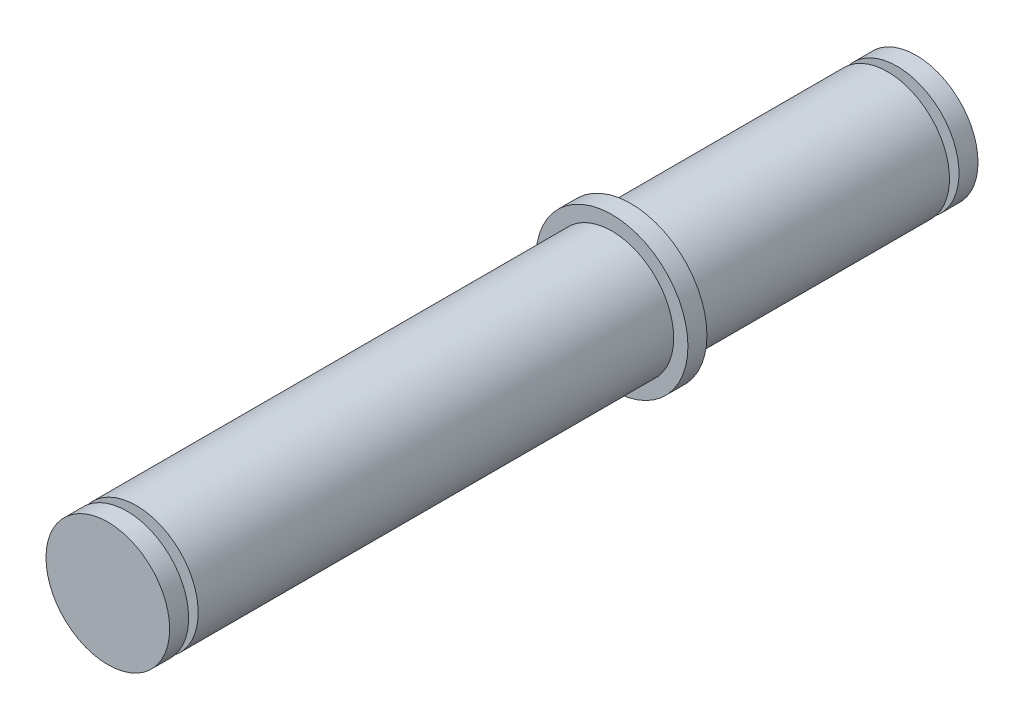
from build123d import *

# Parameters (mm, degrees)
SKETCH1_R           = 6.5
BOSS_EXTRUDE1_DEPTH = 42.5
SKETCH2_R           = 8
BOSS_EXTRUDE2_DEPTH = 2
SKETCH3_R           = 6.5
SKETCH3_R_2         = 4.5
CUT_EXTRUDE1_DEPTH  = 1


with BuildPart() as part:
    # Sketch1 → Boss-Extrude1 (new body, symmetric)
    with BuildSketch(Plane.XY):
        Circle(SKETCH1_R)
    extrude(amount=BOSS_EXTRUDE1_DEPTH, both=True)

    # Sketch2 → Boss-Extrude2 (add)
    with BuildSketch(Plane.XY.offset(-12.5)):
        Circle(SKETCH2_R)
    extrude(amount=BOSS_EXTRUDE2_DEPTH)

    # Sketch3 → Cut-Extrude1 (cut)
    with BuildSketch(Plane(origin=(0, 0, -40.5), x_dir=(-1, 0, 0), z_dir=(0, 0, -1))):
        Circle(SKETCH3_R)
        Circle(SKETCH3_R_2, mode=Mode.SUBTRACT)
    cut_extrude1 = extrude(amount=-CUT_EXTRUDE1_DEPTH, mode=Mode.SUBTRACT)

    # Mirror1: Cut-Extrude1 across plane
    add(cut_extrude1.mirror(Plane.XY), mode=Mode.SUBTRACT)


solid = part.part
